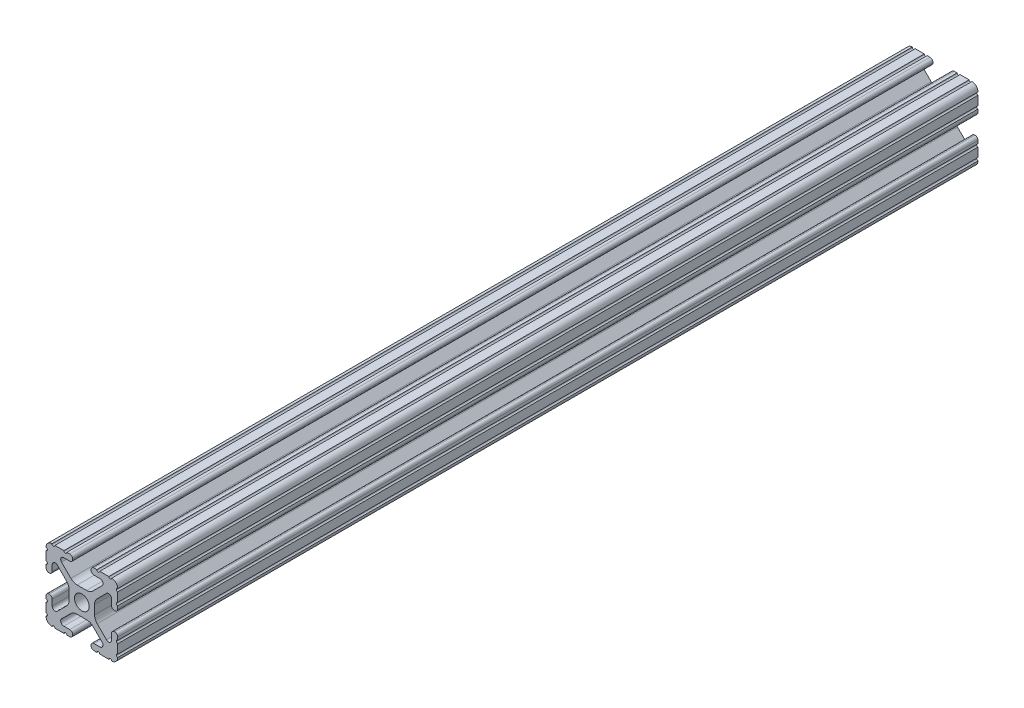
from build123d import *

# Parameters (mm, degrees)
SKETCH1_R               = 2.6035
BOSS_EXTRUDE1_DEPTH     = 152.4
SKETCH2_R               = 3.175
CUT_EXTRUDE1_DEPTH      = 1
CUT_EXTRUDE1_DEPTH_BACK = 26.4
SKETCH3_R               = 3.175
CUT_EXTRUDE2_DEPTH      = 1
CUT_EXTRUDE2_DEPTH_BACK = 26.4


with BuildPart() as part:
    # Sketch1 → Boss-Extrude1 (new body, symmetric)
    with BuildSketch(Plane.XY):
        with BuildLine():
            Line((-7.179650497, -8.645192506), (-3.952270251, -5.423690499))
            ThreePointArc((-3.952270251, -5.423690499), (-2.922936451, -4.736929036), (-1.709253557, -4.4958))
            Line((-1.709253557, -4.4958), (1.709253557, -4.4958))
            ThreePointArc((1.709253557, -4.4958), (2.922936451, -4.736929036), (3.952270251, -5.423690499))
            Line((3.952270251, -5.423690499), (7.179650497, -8.645192506))
            ThreePointArc((7.179650497, -8.645192506), (7.41473083, -9.822813117), (6.416408329, -10.4902))
            Line((6.416408329, -10.4902), (4.287512407, -10.4902))
            ThreePointArc((4.287512407, -10.4902), (3.54574862, -10.79744862), (3.2385, -11.539212407))
            Line((3.2385, -11.539212407), (3.2385, -11.650987593))
            ThreePointArc((3.2385, -11.650987593), (3.54574862, -12.39275138), (4.287512407, -12.7))
            Line((4.287512407, -12.7), (5.317126718, -12.7))
            ThreePointArc((5.317126718, -12.7), (5.825126718, -12.192), (6.333126718, -12.7))
            Line((6.333126718, -12.7), (9.550443118, -12.7))
            ThreePointArc((9.550443118, -12.7), (10.058366869, -12.192000006), (10.566443095, -12.699847501))
            ThreePointArc((10.566443095, -12.699847501), (12.082537762, -12.08250727), (12.699846982, -10.566399977))
            ThreePointArc((12.699846982, -10.566399977), (12.192000006, -10.058323491), (12.7, -9.5504))
            Line((12.7, -9.5504), (12.7, -6.3330836))
            ThreePointArc((12.7, -6.3330836), (12.192, -5.8250836), (12.7, -5.3170836))
            Line((12.7, -5.3170836), (12.7, -4.287469289))
            ThreePointArc((12.7, -4.287469289), (12.39275138, -3.545705502), (11.650987593, -3.238456882))
            Line((11.650987593, -3.238456882), (11.539212407, -3.238456882))
            ThreePointArc((11.539212407, -3.238456882), (10.79744862, -3.545705502), (10.4902, -4.287469289))
            Line((10.4902, -4.287469289), (10.4902, -6.402089023))
            ThreePointArc((10.4902, -6.402089023), (9.856505071, -7.351067942), (8.737131347, -7.129408934))
            Line((8.737131347, -7.129408934), (5.441005833, -3.840816462))
            ThreePointArc((5.441005833, -3.840816462), (4.750877967, -2.809883091), (4.5085, -1.593185507))
            Line((4.5085, -1.593185507), (4.5085, 1.593185507))
            ThreePointArc((4.5085, 1.593185507), (4.750877967, 2.809883091), (5.441005833, 3.840816462))
            Line((5.441005833, 3.840816462), (8.737131347, 7.129408934))
            ThreePointArc((8.737131347, 7.129408934), (9.856505071, 7.351067942), (10.4902, 6.402089023))
            Line((10.4902, 6.402089023), (10.4902, 4.287469289))
            ThreePointArc((10.4902, 4.287469289), (10.79744862, 3.545705502), (11.539212407, 3.238456882))
            Line((11.539212407, 3.238456882), (11.650987593, 3.238456882))
            ThreePointArc((11.650987593, 3.238456882), (12.39275138, 3.545705502), (12.7, 4.287469289))
            Line((12.7, 4.287469289), (12.7, 5.3170836))
            ThreePointArc((12.7, 5.3170836), (12.192, 5.8250836), (12.7, 6.3330836))
            Line((12.7, 6.3330836), (12.7, 9.5504))
            ThreePointArc((12.7, 9.5504), (12.192000006, 10.058323491), (12.699846982, 10.566399977))
            ThreePointArc((12.699846982, 10.566399977), (12.082537762, 12.08250727), (10.566443095, 12.699847501))
            ThreePointArc((10.566443095, 12.699847501), (10.058366869, 12.192000006), (9.550443118, 12.7))
            Line((9.550443118, 12.7), (6.333126718, 12.7))
            ThreePointArc((6.333126718, 12.7), (5.825126718, 12.192), (5.317126718, 12.7))
            Line((5.317126718, 12.7), (4.287512407, 12.7))
            ThreePointArc((4.287512407, 12.7), (3.54574862, 12.39275138), (3.2385, 11.650987593))
            Line((3.2385, 11.650987593), (3.2385, 11.539212407))
            ThreePointArc((3.2385, 11.539212407), (3.54574862, 10.79744862), (4.287512407, 10.4902))
            Line((4.287512407, 10.4902), (6.476788598, 10.4902))
            ThreePointArc((6.476788598, 10.4902), (7.432222385, 9.85140422), (7.207036008, 8.724370562))
            Line((7.207036008, 8.724370562), (3.898272566, 5.423169045))
            ThreePointArc((3.898272566, 5.423169045), (2.869120213, 4.736787962), (1.655778399, 4.4958))
            Line((1.655778399, 4.4958), (-1.655778399, 4.4958))
            ThreePointArc((-1.655778399, 4.4958), (-2.869120213, 4.736787962), (-3.898272566, 5.423169045))
            Line((-3.898272566, 5.423169045), (-7.207036008, 8.724370562))
            ThreePointArc((-7.207036008, 8.724370562), (-7.432222385, 9.85140422), (-6.476788598, 10.4902))
            Line((-6.476788598, 10.4902), (-4.287512407, 10.4902))
            ThreePointArc((-4.287512407, 10.4902), (-3.54574862, 10.79744862), (-3.2385, 11.539212407))
            Line((-3.2385, 11.539212407), (-3.2385, 11.650987593))
            ThreePointArc((-3.2385, 11.650987593), (-3.54574862, 12.39275138), (-4.287512407, 12.7))
            Line((-4.287512407, 12.7), (-5.317126718, 12.7))
            ThreePointArc((-5.317126718, 12.7), (-5.825126718, 12.192), (-6.333126718, 12.7))
            Line((-6.333126718, 12.7), (-9.550443118, 12.7))
            ThreePointArc((-9.550443118, 12.7), (-10.058366869, 12.192000006), (-10.566443095, 12.699847501))
            ThreePointArc((-10.566443095, 12.699847501), (-12.082537762, 12.08250727), (-12.699846982, 10.566399977))
            ThreePointArc((-12.699846982, 10.566399977), (-12.192000006, 10.058323491), (-12.7, 9.5504))
            Line((-12.7, 9.5504), (-12.7, 6.3330836))
            ThreePointArc((-12.7, 6.3330836), (-12.192, 5.8250836), (-12.7, 5.3170836))
            Line((-12.7, 5.3170836), (-12.7, 4.287469289))
            ThreePointArc((-12.7, 4.287469289), (-12.39275138, 3.545705502), (-11.650987593, 3.238456882))
            Line((-11.650987593, 3.238456882), (-11.539212407, 3.238456882))
            ThreePointArc((-11.539212407, 3.238456882), (-10.79744862, 3.545705502), (-10.4902, 4.287469289))
            Line((-10.4902, 4.287469289), (-10.4902, 6.402089023))
            ThreePointArc((-10.4902, 6.402089023), (-9.856505071, 7.351067942), (-8.737131347, 7.129408934))
            Line((-8.737131347, 7.129408934), (-5.441005833, 3.840816462))
            ThreePointArc((-5.441005833, 3.840816462), (-4.750877967, 2.809883091), (-4.5085, 1.593185507))
            Line((-4.5085, 1.593185507), (-4.5085, -1.593185507))
            ThreePointArc((-4.5085, -1.593185507), (-4.750877967, -2.809883091), (-5.441005833, -3.840816462))
            Line((-5.441005833, -3.840816462), (-8.737131347, -7.129408934))
            ThreePointArc((-8.737131347, -7.129408934), (-9.856505071, -7.351067942), (-10.4902, -6.402089023))
            Line((-10.4902, -6.402089023), (-10.4902, -4.287469289))
            ThreePointArc((-10.4902, -4.287469289), (-10.79744862, -3.545705502), (-11.539212407, -3.238456882))
            Line((-11.539212407, -3.238456882), (-11.650987593, -3.238456882))
            ThreePointArc((-11.650987593, -3.238456882), (-12.39275138, -3.545705502), (-12.7, -4.287469289))
            Line((-12.7, -4.287469289), (-12.7, -5.3170836))
            ThreePointArc((-12.7, -5.3170836), (-12.192, -5.8250836), (-12.7, -6.3330836))
            Line((-12.7, -6.3330836), (-12.7, -9.5504))
            ThreePointArc((-12.7, -9.5504), (-12.192000006, -10.058323491), (-12.699846982, -10.566399977))
            ThreePointArc((-12.699846982, -10.566399977), (-12.082537762, -12.08250727), (-10.566443095, -12.699847501))
            ThreePointArc((-10.566443095, -12.699847501), (-10.058366869, -12.192000006), (-9.550443118, -12.7))
            Line((-9.550443118, -12.7), (-6.333126718, -12.7))
            ThreePointArc((-6.333126718, -12.7), (-5.825126718, -12.192), (-5.317126718, -12.7))
            Line((-5.317126718, -12.7), (-4.287512407, -12.7))
            ThreePointArc((-4.287512407, -12.7), (-3.54574862, -12.39275138), (-3.2385, -11.650987593))
            Line((-3.2385, -11.650987593), (-3.2385, -11.539212407))
            ThreePointArc((-3.2385, -11.539212407), (-3.54574862, -10.79744862), (-4.287512407, -10.4902))
            Line((-4.287512407, -10.4902), (-6.416408329, -10.4902))
            ThreePointArc((-6.416408329, -10.4902), (-7.41473083, -9.822813117), (-7.179650497, -8.645192506))
        make_face()
        Circle(SKETCH1_R, mode=Mode.SUBTRACT)
    extrude(amount=BOSS_EXTRUDE1_DEPTH, both=True)

    # Sketch2 → Cut-Extrude1 (cut, two sides)
    with BuildSketch(Plane(origin=(0, 12.7, 0), x_dir=(1, 0, 0), z_dir=(0, 1, 0))) as cut_extrude1_sk:
        with Locations((0, -88.9)):
            Circle(SKETCH2_R)
        with Locations((0, 127)):
            Circle(SKETCH2_R)
    extrude(amount=CUT_EXTRUDE1_DEPTH, mode=Mode.SUBTRACT)
    extrude(cut_extrude1_sk.sketch, amount=-CUT_EXTRUDE1_DEPTH_BACK, mode=Mode.SUBTRACT)

    # Sketch3 → Cut-Extrude2 (cut, two sides)
    with BuildSketch(Plane.ZY.offset(12.7)) as cut_extrude2_sk:
        with Locations((-101.6, 0)):
            Circle(SKETCH3_R)
        with Locations((63.5, 0)):
            Circle(SKETCH3_R)
    extrude(amount=CUT_EXTRUDE2_DEPTH, mode=Mode.SUBTRACT)
    extrude(cut_extrude2_sk.sketch, amount=-CUT_EXTRUDE2_DEPTH_BACK, mode=Mode.SUBTRACT)


solid = part.part
